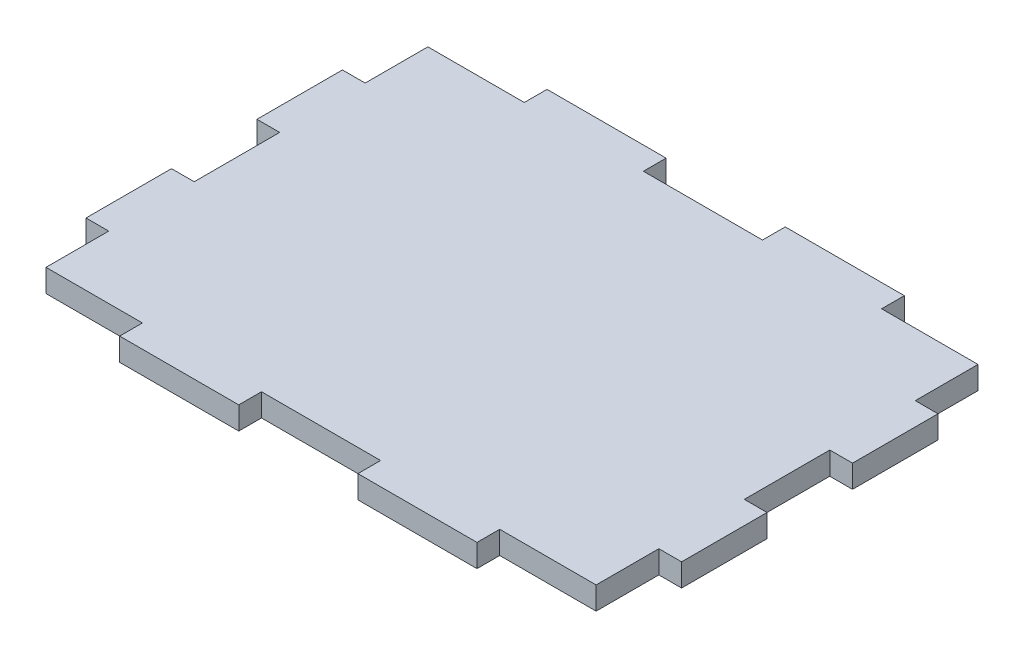
from build123d import *

# Parameters (mm, degrees)
SKETCH1_W           = 83.185
SKETCH1_H           = 59.69
BOSS_EXTRUDE1_DEPTH = 3.175
SKETCH2_W           = 16.637
SKETCH2_H           = 3.175
CUT_EXTRUDE1_DEPTH  = 3.175
LPATTERN1_COUNT     = 3
LPATTERN1_PITCH     = 33.274
SKETCH3_W           = 3.175
SKETCH3_H           = 11.938
CUT_EXTRUDE2_DEPTH  = 3.175
LPATTERN4_COUNT     = 3
LPATTERN4_PITCH     = 23.876


with BuildPart() as part:
    # Sketch1 → Boss-Extrude1 (new body)
    with BuildSketch(Plane(origin=(0, 0, 0), x_dir=(1, 0, 0), z_dir=(0, 1, 0))):
        Rectangle(SKETCH1_W, SKETCH1_H)
    extrude(amount=BOSS_EXTRUDE1_DEPTH)

    # Sketch2 → Cut-Extrude1 (cut)
    with BuildSketch(Plane(origin=(0, 3.175, 0), x_dir=(1, 0, 0), z_dir=(0, 1, 0))):
        with Locations((-33.274, 28.2575)):
            Rectangle(SKETCH2_W, SKETCH2_H)
        with Locations((-33.274, -28.2575)):
            Rectangle(SKETCH2_W, SKETCH2_H)
    cut_extrude1 = extrude(amount=-CUT_EXTRUDE1_DEPTH, mode=Mode.SUBTRACT)

    # LPattern1: Cut-Extrude1 ×3
    with Locations(*[(i * LPATTERN1_PITCH, 0, 0) for i in range(1, LPATTERN1_COUNT)]):
        add(cut_extrude1, mode=Mode.SUBTRACT)

    # Sketch3 → Cut-Extrude2 (cut)
    with BuildSketch(Plane(origin=(0, 3.175, 0), x_dir=(1, 0, 0), z_dir=(0, 1, 0))):
        with Locations((-40.005, 23.876)):
            Rectangle(SKETCH3_W, SKETCH3_H)
        with Locations((40.005, 23.876)):
            Rectangle(SKETCH3_W, SKETCH3_H)
    cut_extrude2 = extrude(amount=-CUT_EXTRUDE2_DEPTH, mode=Mode.SUBTRACT)

    # LPattern4: Cut-Extrude2 ×3
    with Locations(*[(0, 0, i * LPATTERN4_PITCH) for i in range(1, LPATTERN4_COUNT)]):
        add(cut_extrude2, mode=Mode.SUBTRACT)


solid = part.part
